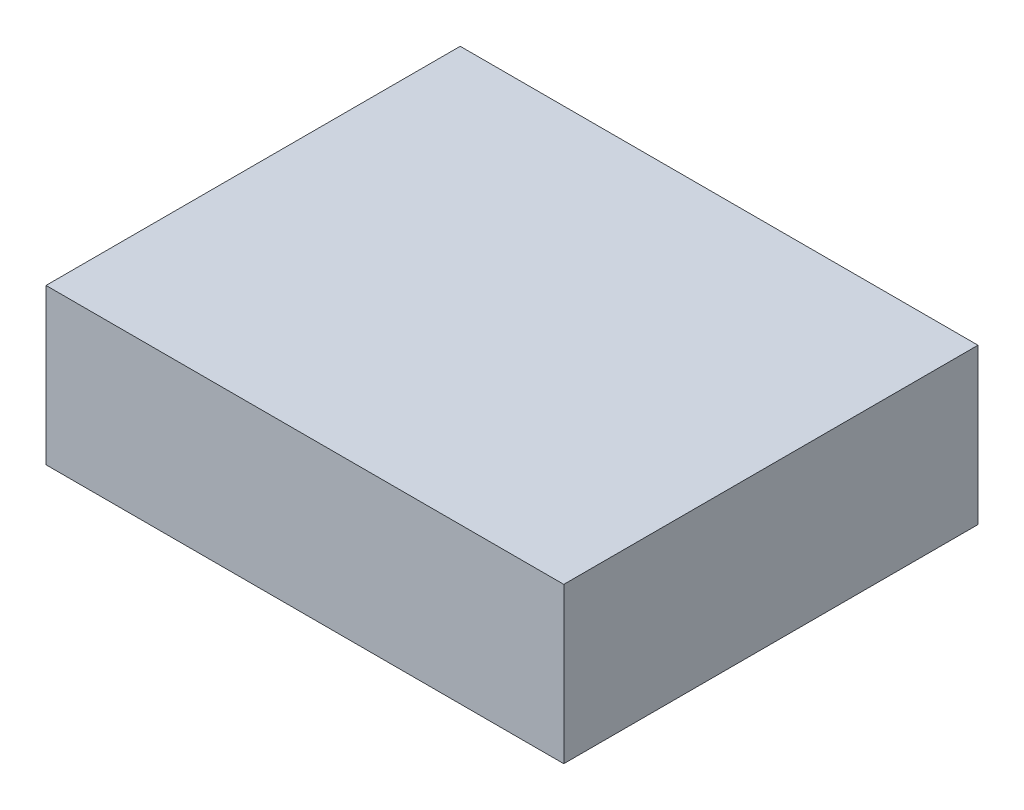
from build123d import *

# Parameters (mm, degrees)
SKETCH1_W           = 100
SKETCH1_H           = 80
BOSS_EXTRUDE1_DEPTH = 30


with BuildPart() as part:
    # Sketch1 → Boss-Extrude1 (new body)
    with BuildSketch(Plane(origin=(0, 0, 0), x_dir=(1, 0, 0), z_dir=(0, 1, 0))):
        Rectangle(SKETCH1_W, SKETCH1_H)
    extrude(amount=BOSS_EXTRUDE1_DEPTH)


solid = part.part
